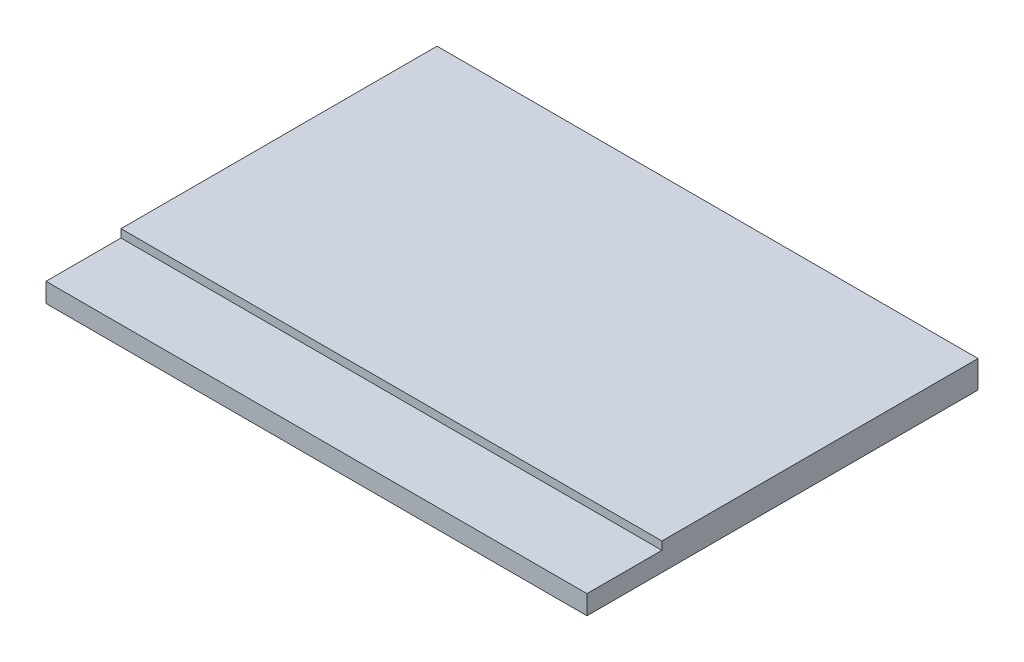
from build123d import *

# Parameters (mm, degrees)
SKETCH1_W           = 26.7
SKETCH1_H           = 19.3
BOSS_EXTRUDE1_DEPTH = 1.35
SKETCH2_W           = 26.7
SKETCH2_H           = 3.7
CUT_EXTRUDE1_DEPTH  = 0.4


with BuildPart() as part:
    # Sketch1 → Boss-Extrude1 (new body)
    with BuildSketch(Plane(origin=(0, 0, 0), x_dir=(1, 0, 0), z_dir=(0, 1, 0))):
        Rectangle(SKETCH1_W, SKETCH1_H)
    extrude(amount=BOSS_EXTRUDE1_DEPTH)

    # Sketch2 → Cut-Extrude1 (cut)
    with BuildSketch(Plane(origin=(0, 1.35, 0), x_dir=(1, 0, 0), z_dir=(0, 1, 0))):
        with Locations((0, -7.8)):
            Rectangle(SKETCH2_W, SKETCH2_H)
    extrude(amount=-CUT_EXTRUDE1_DEPTH, mode=Mode.SUBTRACT)


solid = part.part
